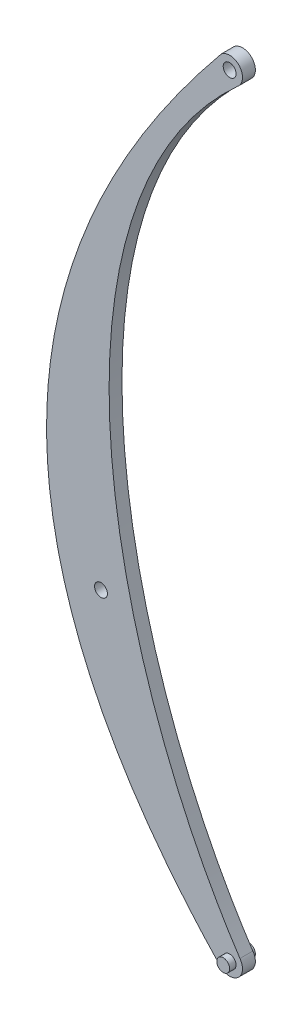
from build123d import *

# Parameters (mm, degrees)
SKETCH1_R           = 5
BOSS_EXTRUDE1_DEPTH = 5
SKETCH1_3_R         = 5
BOSS_EXTRUDE2_DEPTH = 10


with BuildPart() as part:
    # Sketch1 → Boss-Extrude1 (new body)
    with BuildSketch(Plane.XY):
        with BuildLine():
            ThreePointArc((-7.07496458, -7.067168895), (6.531960096, -7.571888622), (8.028425575, 5.961911001))
            add(Edge.make_bspline(
                [(6.054624404, 592.041261198), (-154.861931166, 445.129888812), (-96.296929143, 163.306236232), (8.028425575, 5.961911001)],
                knots=[0, 0, 0, 0, 1, 1, 1, 1], degree=3))
            ThreePointArc((6.054624404, 592.041261198), (7.812843537, 606.241752628), (-6.425366596, 607.662549452))
            add(Edge.make_bspline(
                [(-6.425366596, 607.662549452), (-277.843168438, 277.304372569), (-7.07496458, -7.067168895)],
                knots=[0, 0, 0, 1, 1, 1], degree=2))
        make_face()
        Circle(SKETCH1_R, mode=Mode.SUBTRACT)
        with Locations((-100, 200)):
            Circle(SKETCH1_R, mode=Mode.SUBTRACT)
        with Locations((0, 600)):
            Circle(SKETCH1_R, mode=Mode.SUBTRACT)
    boss_extrude1 = extrude(amount=BOSS_EXTRUDE1_DEPTH)

    # Sketch1_3 → Boss-Extrude2 (add)
    with BuildSketch(Plane.XY):
        Circle(SKETCH1_3_R)
    boss_extrude2 = extrude(amount=BOSS_EXTRUDE2_DEPTH)

    # Mirror1: Boss-Extrude1, Boss-Extrude2 across plane
    add(boss_extrude1.mirror(Plane.XY))
    add(boss_extrude2.mirror(Plane.XY))


solid = part.part
